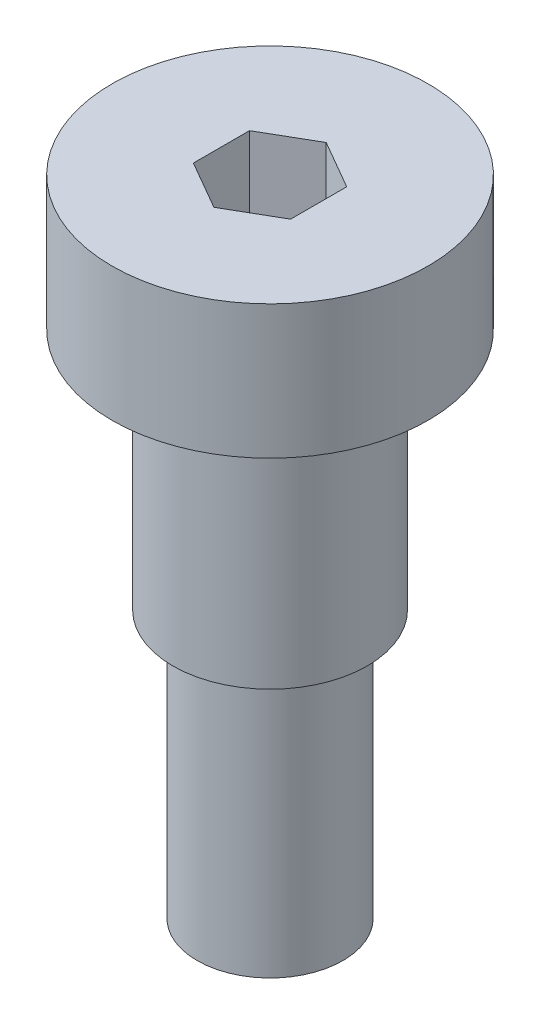
from build123d import *

# Parameters (mm, degrees)
SOCKET_DEPTH = 3


with BuildPart() as part:
    # profile → Base-Revolve (revolve)
    with BuildSketch(Plane.XY):
        Polygon((0, 5.5), (6.5, 5.5), (6.5, 0), (4, 0), (4, -10), (3, -10), (3, -21), (0, -21), align=None)
    revolve(axis=Axis((0, 24.832359952, 0), (0, -1, 0)))

    # socket shape → socket (cut)
    with BuildSketch(Plane(origin=(0, 5.5, 0), x_dir=(-1, 0, 0), z_dir=(0, 1, 0))):
        Polygon((0, 2.309401077), (-2, 1.154700538), (-2, -1.154700538), (0, -2.309401077), (2, -1.154700538), (2, 1.154700538), align=None)
    extrude(amount=-SOCKET_DEPTH, mode=Mode.SUBTRACT)


solid = part.part
